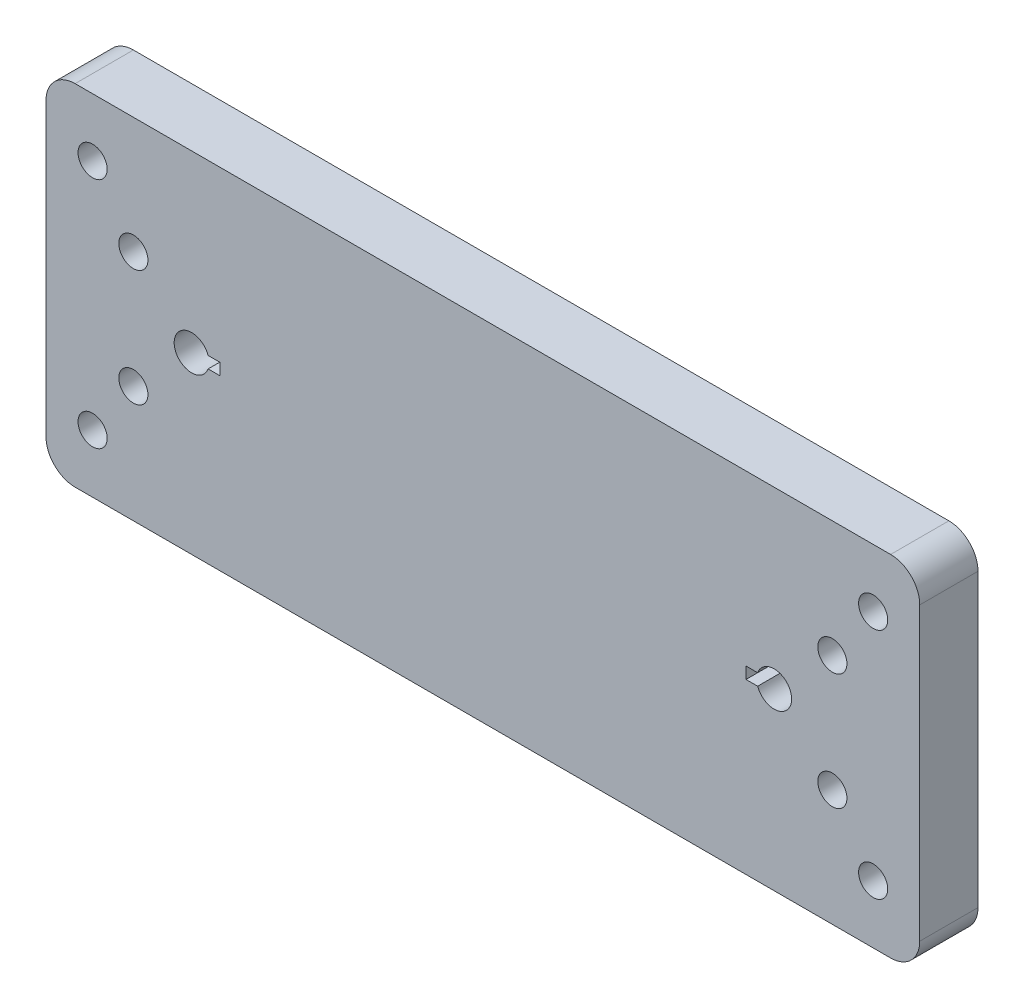
from build123d import *

# Parameters (mm, degrees)
BOSS_EXTRUDE1_DEPTH = 10
SKETCH2_R           = 2.5
CUT_EXTRUDE1_DEPTH  = 11
SKETCH3_R           = 2.5
CUT_EXTRUDE3_DEPTH  = 11


with BuildPart() as part:
    # Sketch1 → Boss-Extrude1 (new body)
    with BuildSketch(Plane.XY):
        with BuildLine():
            Line((5, 0), (145, 0))
            ThreePointArc((145, 0), (148.535533906, 1.464466094), (150, 5))
            Line((150, 5), (150, 55))
            ThreePointArc((150, 55), (148.535533906, 58.535533906), (145, 60))
            Line((145, 60), (5, 60))
            ThreePointArc((5, 60), (1.464466094, 58.535533906), (0, 55))
            Line((0, 55), (0, 5))
            ThreePointArc((0, 5), (1.464466094, 1.464466094), (5, 0))
        make_face()
        with BuildLine():
            Line((27.828427125, 31), (29.828427125, 31))
            Line((29.828427125, 31), (29.828427125, 29))
            Line((29.828427125, 29), (27.828427125, 29))
            ThreePointArc((27.828427125, 29), (22, 30), (27.828427125, 31))
        make_face(mode=Mode.SUBTRACT)
        with BuildLine():
            Line((122.171572875, 31), (120.171572875, 31))
            Line((120.171572875, 31), (120.171572875, 29))
            Line((120.171572875, 29), (122.171572875, 29))
            ThreePointArc((122.171572875, 29), (128, 30), (122.171572875, 31))
        make_face(mode=Mode.SUBTRACT)
    extrude(amount=BOSS_EXTRUDE1_DEPTH)

    # Sketch2 → Cut-Extrude1 (cut, through all)
    with BuildSketch(Plane.XY.offset(10)):
        with Locations((15, 40)):
            Circle(SKETCH2_R)
        with Locations((15, 20)):
            Circle(SKETCH2_R)
        with Locations((135, 40)):
            Circle(SKETCH2_R)
        with Locations((135, 20)):
            Circle(SKETCH2_R)
    extrude(amount=-CUT_EXTRUDE1_DEPTH, mode=Mode.SUBTRACT)

    # Sketch3 → Cut-Extrude3 (cut, through all)
    with BuildSketch(Plane.XY.offset(10)):
        with Locations((8, 50)):
            Circle(SKETCH3_R)
        with Locations((8, 10)):
            Circle(SKETCH3_R)
        with Locations((142, 50)):
            Circle(SKETCH3_R)
        with Locations((142, 10)):
            Circle(SKETCH3_R)
    extrude(amount=-CUT_EXTRUDE3_DEPTH, mode=Mode.SUBTRACT)


solid = part.part
